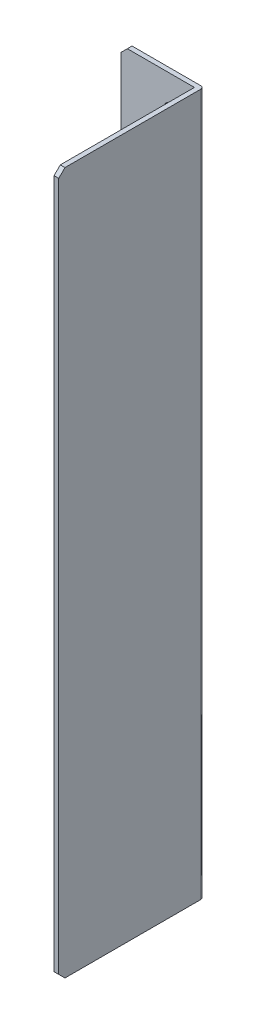
from build123d import *

# Parameters (mm, degrees)
BOSS_EXTRUDE1_DEPTH = 1.5
SKETCH2_W           = 1.5
SKETCH2_H           = 225
BOSS_EXTRUDE2_DEPTH = 45
CHAMFER1_SIZE       = 2
FILLET1_R           = 1
SKETCH3_R           = 2.25
CUT_EXTRUDE1_DEPTH  = 2.5


with BuildPart() as part:
    # Sketch1 → Boss-Extrude1 (new body)
    with BuildSketch(Plane.XY):
        Polygon((-12.96728972, 188.376168224), (12.03271028, 188.376168224), (12.03271028, -36.623831776), (-7.96728972, -36.623831776), (-7.96728972, -26.623831776), (-12.96728972, -26.623831776), align=None)
    extrude(amount=BOSS_EXTRUDE1_DEPTH)

    # Sketch2 → Boss-Extrude2 (add)
    with BuildSketch(Plane.XY.offset(1.5)):
        with Locations((11.28271028, 75.876168224)):
            Rectangle(SKETCH2_W, SKETCH2_H)
    extrude(amount=BOSS_EXTRUDE2_DEPTH)

    # Chamfer1
    chamfer1_edges = [part.edges().sort_by_distance(p)[0] for p in [
        (-12.96728972, 188.376168224, 0.75),
        (11.28271028, 188.376168224, 46.5),
        (11.28271028, -36.623831776, 46.5),
    ]]
    chamfer(chamfer1_edges, length=CHAMFER1_SIZE)

    # Fillet1
    fillet1_edges = [part.edges().sort_by_distance(p)[0] for p in [
        (12.03271028, 75.876168224, 0),
    ]]
    fillet(fillet1_edges, radius=FILLET1_R)

    # Sketch3 → Cut-Extrude1 (cut, through all)
    with BuildSketch(Plane.XY.offset(1.5)):
        with Locations((3.03271028, 177.946548893)):
            Circle(SKETCH3_R)
        with Locations((3.03271028, -29.014631464)):
            Circle(SKETCH3_R)
    extrude(amount=-CUT_EXTRUDE1_DEPTH, mode=Mode.SUBTRACT)


solid = part.part
